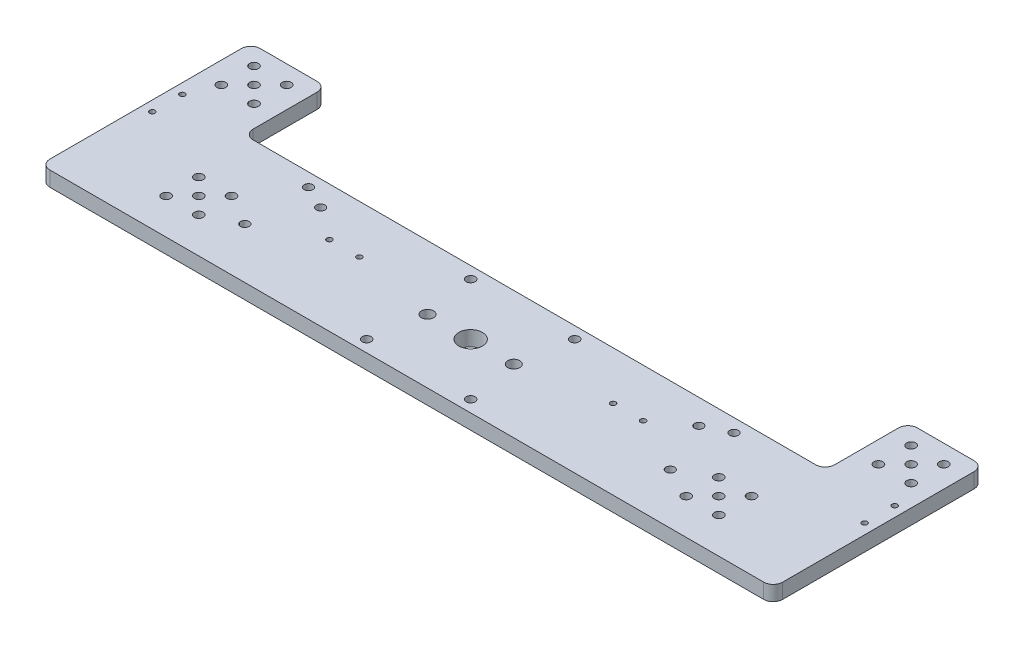
from build123d import *

# Parameters (mm, degrees)
BOSS_EXTRUDE1_DEPTH                = 6.35
SKETCH2_R                          = 5
CUT_EXTRUDE1_DEPTH                 = 7.35
F_6_CLEARANCE_HOLE1_D              = 3.7973
F_6_CLEARANCE_HOLE1_DEPTH          = 10
F_6_CLEARANCE_HOLE1_TIP            = 1.140824014
FILLET1_R                          = 4
F_10_CLEARANCE_HOLE1_D             = 5.1054
F_10_CLEARANCE_HOLE1_DEPTH         = 10
F_10_CLEARANCE_HOLE1_TIP           = 1.533816902
F_6_CLEARANCE_HOLE2_D              = 3.6576
TAP_DRILL_FOR_4_40_TAP1_AT_2_COUNT = 2
TAP_DRILL_FOR_4_40_TAP1_AT_2_PITCH = 12.7
TAP_DRILL_FOR_4_40_TAP1_AT_3_COUNT = 2
TAP_DRILL_FOR_4_40_TAP1_AT_3_PITCH = 87.179331478
TAP_DRILL_FOR_4_40_TAP1_AT_4_COUNT = 2
TAP_DRILL_FOR_4_40_TAP1_AT_4_PITCH = 99.516880161


with BuildPart() as part:
    # Sketch1 → Boss-Extrude1 (new body)
    with BuildSketch(Plane(origin=(0, 0, 0), x_dir=(1, 0, 0), z_dir=(0, 1, 0))):
        Polygon((-155, -27), (155, -27), (155, 27), (155, 62), (123, 62), (123, 27), (-123, 27), (-123, 62), (-155, 62), (-155, 27), align=None)
    extrude(amount=BOSS_EXTRUDE1_DEPTH)

    # Sketch2 → Cut-Extrude1 (cut, through all)
    with BuildSketch(Plane(origin=(0, 6.35, 0), x_dir=(1, 0, 0), z_dir=(0, 1, 0))):
        Circle(SKETCH2_R)
    extrude(amount=-CUT_EXTRUDE1_DEPTH, mode=Mode.SUBTRACT)

    # #6 Clearance Hole1
    with Locations(Plane(origin=(-145.915, 6.35, -54.265), x_dir=(0, 0, 1), z_dir=(0, 1, 0))):
        with Locations((0, 0), (0, 13.83), (13.83, 13.83), (13.83, 0), (6.915, 6.915), (52.35, 29), (52.35, 42.83), (66.18, 42.83), (66.18, 29), (59.265, 35.915), (32.265, 123.915), (32.265, 167.915), (76.265, 167.915), (76.265, 123.915), (66.18, 249), (52.35, 249), (52.35, 262.83), (66.18, 262.83), (59.265, 255.915), (13.83, 278), (6.915, 284.915), (0, 278), (0, 291.83), (13.83, 291.83)):
            Hole(F_6_CLEARANCE_HOLE1_D / 2, depth=F_6_CLEARANCE_HOLE1_DEPTH)
            with Locations((0, 0, -(F_6_CLEARANCE_HOLE1_DEPTH + F_6_CLEARANCE_HOLE1_TIP / 2))):  # 118° drill point
                Cone(0, F_6_CLEARANCE_HOLE1_D / 2, F_6_CLEARANCE_HOLE1_TIP, mode=Mode.SUBTRACT)

    # Fillet1
    fillet1_edges = [part.edges().sort_by_distance(p)[0] for p in [
        (155, 3.175, 27),
        (-155, 3.175, 27),
        (-155, 3.175, -62),
        (-123, 3.175, -62),
        (-123, 3.175, -27),
        (123, 3.175, -27),
        (123, 3.175, -62),
        (155, 3.175, -62),
    ]]
    fillet(fillet1_edges, radius=FILLET1_R)

    # #10 Clearance Hole1
    with Locations(Plane(origin=(-18.25, 6.35, 0), x_dir=(0, 0, 1), z_dir=(0, 1, 0))):
        with Locations((0, 0), (0, 36.5)):
            Hole(F_10_CLEARANCE_HOLE1_D / 2, depth=F_10_CLEARANCE_HOLE1_DEPTH)
            with Locations((0, 0, -(F_10_CLEARANCE_HOLE1_DEPTH + F_10_CLEARANCE_HOLE1_TIP / 2))):  # 118° drill point
                Cone(0, F_10_CLEARANCE_HOLE1_D / 2, F_10_CLEARANCE_HOLE1_TIP, mode=Mode.SUBTRACT)

    # #6 Clearance Hole2 (through all)
    with Locations(Plane(origin=(0, 6.35, 0), x_dir=(-1, 0, 0), z_dir=(0, 1, 0))):
        with Locations((90, -21.412), (90, 5.5374), (-90, 5.5374), (-90, -21.412), (80, -16.5352), (-80, -16.5352)):
            Hole(F_6_CLEARANCE_HOLE2_D / 2)

    # Sketch11 → Tap Drill for #4-40 Tap1 (revolve, cut)
    with BuildSketch(Plane(origin=(-150.684, 6.35, -28.7), x_dir=(0, 0, 1), z_dir=(1, 0, 0))):
        Polygon((0, 0), (0, 7.029152758), (1.1303, 6.35), (1.1303, 0), align=None)
    tap_drill_for_4_40_tap1 = revolve(axis=Axis((-150.684, 12.7, -28.7), (0, -1, 0)), mode=Mode.SUBTRACT)

    # Tap Drill for #4-40 Tap1 at 2: Tap Drill for #4-40 Tap1 ×2
    with Locations(*[(0, 0, i * TAP_DRILL_FOR_4_40_TAP1_AT_2_PITCH) for i in range(1, TAP_DRILL_FOR_4_40_TAP1_AT_2_COUNT)]):
        add(tap_drill_for_4_40_tap1, mode=Mode.SUBTRACT)

    # Tap Drill for #4-40 Tap1 at 3: Tap Drill for #4-40 Tap1 ×2
    with Locations(*[Vector(0.967362316, 0, 0.253397217) * (i * TAP_DRILL_FOR_4_40_TAP1_AT_3_PITCH) for i in range(1, TAP_DRILL_FOR_4_40_TAP1_AT_3_COUNT)]):
        add(tap_drill_for_4_40_tap1, mode=Mode.SUBTRACT)

    # Tap Drill for #4-40 Tap1 at 4: Tap Drill for #4-40 Tap1 ×2
    with Locations(*[Vector(0.975050663, 0, 0.221982441) * (i * TAP_DRILL_FOR_4_40_TAP1_AT_4_PITCH) for i in range(1, TAP_DRILL_FOR_4_40_TAP1_AT_4_COUNT)]):
        add(tap_drill_for_4_40_tap1, mode=Mode.SUBTRACT)

    # Mirror1: Tap Drill for #4-40 Tap1 across plane
    add(tap_drill_for_4_40_tap1.mirror(Plane(origin=(0, 0, 0), x_dir=(0, 0, 1), z_dir=(1, 0, 0))), mode=Mode.SUBTRACT)

    # Mirror1 copy 1 sketch → Mirror1 copy 1 (revolve, cut)
    with BuildSketch(Plane(origin=(150.684, 6.35, -16), x_dir=(0, 0, 1), z_dir=(-1, 0, 0))):
        Polygon((0, 0), (0, -7.029152758), (1.1303, -6.35), (1.1303, 0), align=None)
    revolve(axis=Axis((150.684, 12.7, -16), (0, 1, 0)), mode=Mode.SUBTRACT)

    # Mirror1 copy 2 sketch → Mirror1 copy 2 (revolve, cut)
    with BuildSketch(Plane(origin=(66.35, 6.35, -6.609), x_dir=(0, 0, 1), z_dir=(-1, 0, 0))):
        Polygon((0, 0), (0, -7.029152758), (1.1303, -6.35), (1.1303, 0), align=None)
    revolve(axis=Axis((66.35, 12.7, -6.609), (0, 1, 0)), mode=Mode.SUBTRACT)

    # Mirror1 copy 3 sketch → Mirror1 copy 3 (revolve, cut)
    with BuildSketch(Plane(origin=(53.65, 6.35, -6.609), x_dir=(0, 0, 1), z_dir=(-1, 0, 0))):
        Polygon((0, 0), (0, -7.029152758), (1.1303, -6.35), (1.1303, 0), align=None)
    revolve(axis=Axis((53.65, 12.7, -6.609), (0, 1, 0)), mode=Mode.SUBTRACT)


solid = part.part
